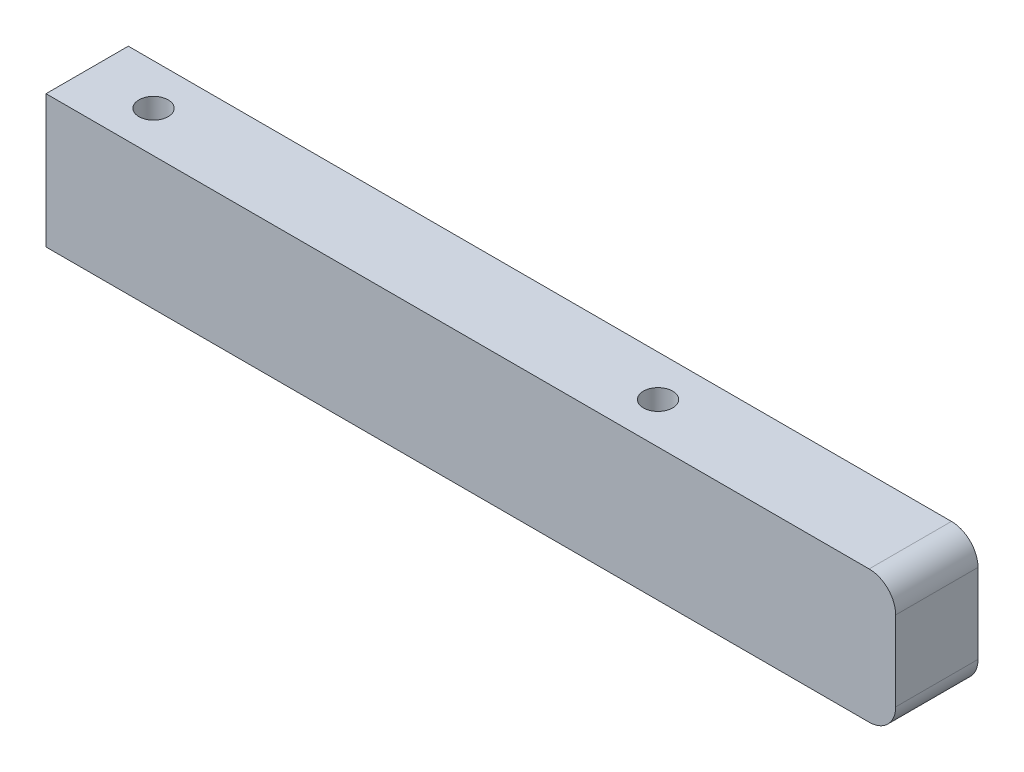
from build123d import *

# Parameters (mm, degrees)
SKETCH1_W                                           = 15.5
SKETCH1_H                                           = 25
BOSS_EXTRUDE1_DEPTH                                 = 80
CBORE_FOR_M5_HEX_SOCKET_HEAD_CAP_SCREW1_D           = 5.5
CBORE_FOR_M5_HEX_SOCKET_HEAD_CAP_SCREW1_CBORE_D     = 10
CBORE_FOR_M5_HEX_SOCKET_HEAD_CAP_SCREW1_CBORE_DEPTH = 5.4
FILLET1_R                                           = 5
FILLET2_R                                           = 5


with BuildPart() as part:
    # Sketch1 → Boss-Extrude1 (new body, symmetric)
    with BuildSketch(Plane(origin=(0, 0, 0), x_dir=(0, 0, -1), z_dir=(1, 0, 0))):
        Rectangle(SKETCH1_W, SKETCH1_H)
    extrude(amount=BOSS_EXTRUDE1_DEPTH, both=True)

    # CBORE for M5 Hex Socket Head Cap Screw1 (through all)
    with Locations(Plane(origin=(0, -12.5, 0), x_dir=(-1, 0, 0), z_dir=(0, -1, 0))):
        with Locations((-27.5, 0), (67.5, 0)):
            CounterBoreHole(CBORE_FOR_M5_HEX_SOCKET_HEAD_CAP_SCREW1_D / 2, CBORE_FOR_M5_HEX_SOCKET_HEAD_CAP_SCREW1_CBORE_D / 2, CBORE_FOR_M5_HEX_SOCKET_HEAD_CAP_SCREW1_CBORE_DEPTH)

    # Fillet1
    fillet1_edges = [part.edges().sort_by_distance(p)[0] for p in [
        (80, -12.5, 0),
    ]]
    fillet(fillet1_edges, radius=FILLET1_R)

    # Fillet2
    fillet2_edges = [part.edges().sort_by_distance(p)[0] for p in [
        (80, 12.5, 0),
    ]]
    fillet(fillet2_edges, radius=FILLET2_R)


solid = part.part
